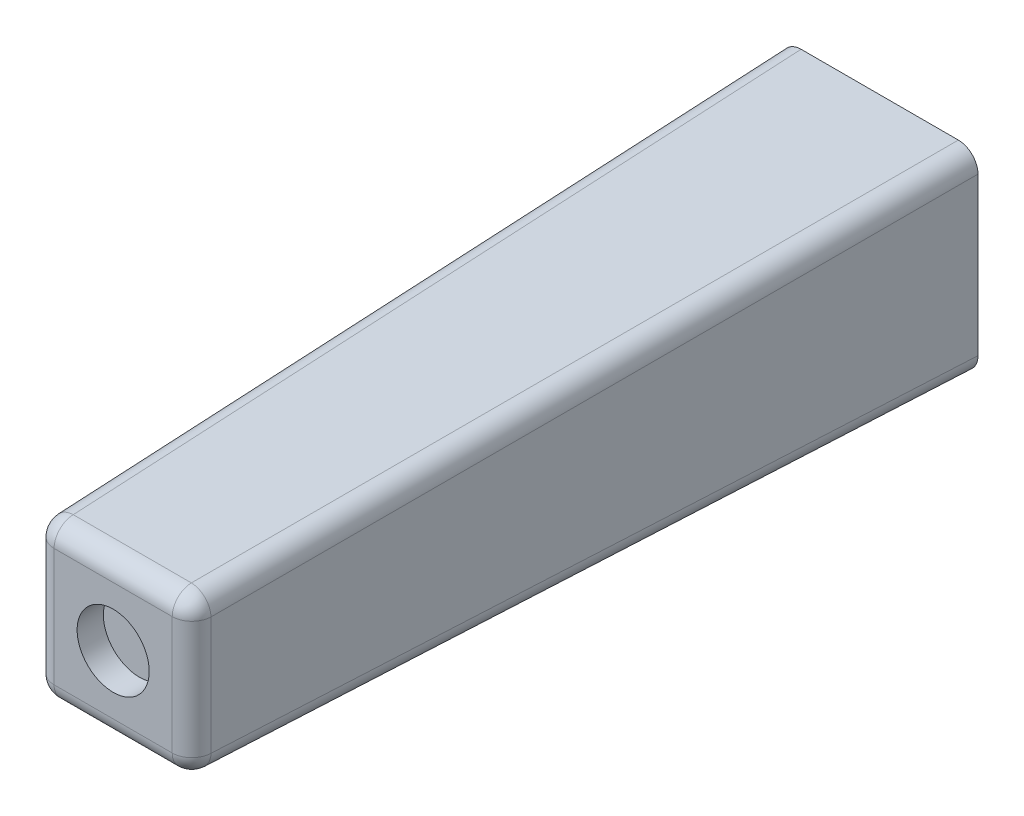
from build123d import *

# Parameters (mm, degrees)
SKETCH1_W           = 15
SKETCH1_H           = 15
BOSS_EXTRUDE1_DEPTH = 58.5
BOSS_EXTRUDE1_TAPER = 1.5
SKETCH2_R           = 1.5
CUT_EXTRUDE1_DEPTH  = 10
SKETCH3_R           = 2.75
CUT_EXTRUDE2_DEPTH  = 2
FILLET1_R           = 1.5
FILLET2_R           = 0.5


with BuildPart() as part:
    # Sketch1 → Boss-Extrude1 (new body)
    with BuildSketch(Plane.XY):
        Rectangle(SKETCH1_W, SKETCH1_H)
    extrude(amount=BOSS_EXTRUDE1_DEPTH, taper=BOSS_EXTRUDE1_TAPER)

    # Sketch2 → Cut-Extrude1 (cut)
    with BuildSketch(Plane(origin=(0, 0, 0), x_dir=(-1, 0, 0), z_dir=(0, 0, -1))):
        Circle(SKETCH2_R)
    extrude(amount=-CUT_EXTRUDE1_DEPTH, mode=Mode.SUBTRACT)

    # Sketch3 → Cut-Extrude2 (cut)
    with BuildSketch(Plane.XY.offset(58.5)):
        Circle(SKETCH3_R)
    extrude(amount=-CUT_EXTRUDE2_DEPTH, mode=Mode.SUBTRACT)

    # Fillet1
    fillet1_edges = [part.edges().sort_by_distance(p)[0] for p in [
        (-5.968123588, 0, 58.5),
        (0, -5.968123588, 58.5),
        (5.968123588, 0, 58.5),
        (6.734061794, -6.734061794, 29.25),
        (-6.734061794, -6.734061794, 29.25),
        (-6.734061332, 6.734061332, 29.250017641),
        (6.734061794, 6.734061794, 29.25),
        (0, 5.968123588, 58.5),
    ]]
    fillet(fillet1_edges, radius=FILLET1_R)

    # Fillet2
    fillet2_edges = [part.edges().sort_by_distance(p)[0] for p in [
        (1.5, 0, 0),
    ]]
    fillet(fillet2_edges, radius=FILLET2_R)


solid = part.part
